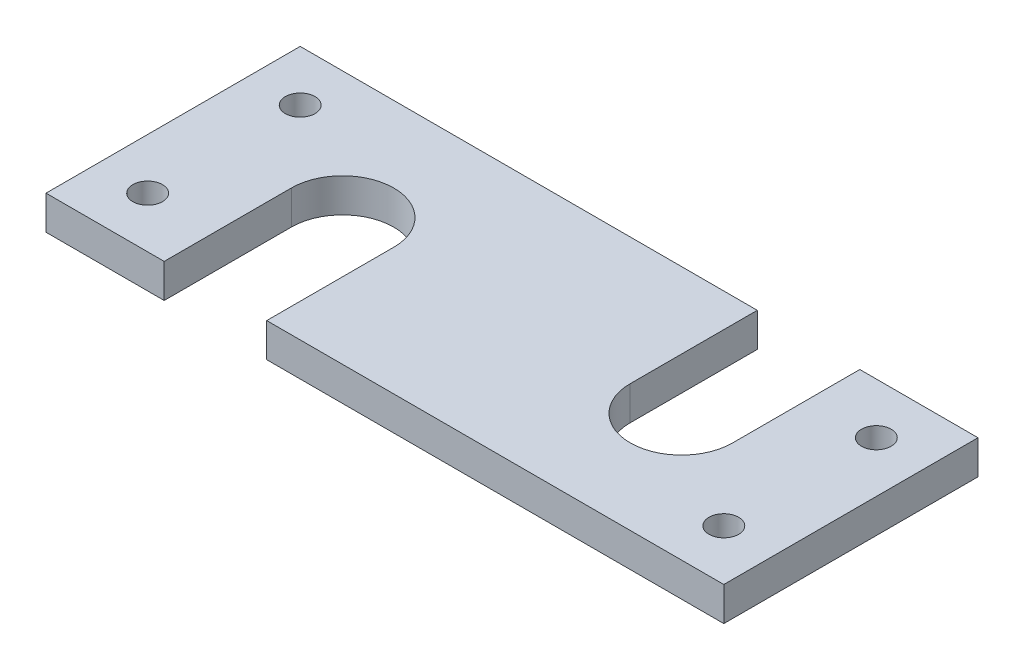
from build123d import *

# Parameters (mm, degrees)
SKETCH2_W           = 80
SKETCH2_H           = 30
BOSS_EXTRUDE1_DEPTH = 4
SKETCH3_R           = 1.75
CUT_EXTRUDE1_DEPTH  = 5


with BuildPart() as part:
    # Sketch2 → Boss-Extrude1 (new body)
    with BuildSketch(Plane(origin=(0, 0, 0), x_dir=(1, 0, 0), z_dir=(0, 1, 0))):
        with Locations((40, 15)):
            Rectangle(SKETCH2_W, SKETCH2_H)
    extrude(amount=BOSS_EXTRUDE1_DEPTH)

    # Sketch3 → Cut-Extrude1 (cut, through all)
    with BuildSketch(Plane(origin=(0, 4, 0), x_dir=(1, 0, 0), z_dir=(0, 1, 0))):
        with Locations((6, 6)):
            Circle(SKETCH3_R)
        with Locations((6, 24)):
            Circle(SKETCH3_R)
        with Locations((74, 24)):
            Circle(SKETCH3_R)
        with Locations((74, 6)):
            Circle(SKETCH3_R)
        with BuildLine():
            Line((13.95, 0), (26.05, 0))
            Line((26.05, 0), (26.05, 15))
            ThreePointArc((26.05, 15), (20, 21.05), (13.95, 15))
            Line((13.95, 15), (13.95, 0))
        make_face()
        with BuildLine():
            Line((53.95, 30), (53.95, 15))
            ThreePointArc((53.95, 15), (60, 8.95), (66.05, 15))
            Line((66.05, 15), (66.05, 30))
            Line((66.05, 30), (53.95, 30))
        make_face()
    extrude(amount=-CUT_EXTRUDE1_DEPTH, mode=Mode.SUBTRACT)


solid = part.part
